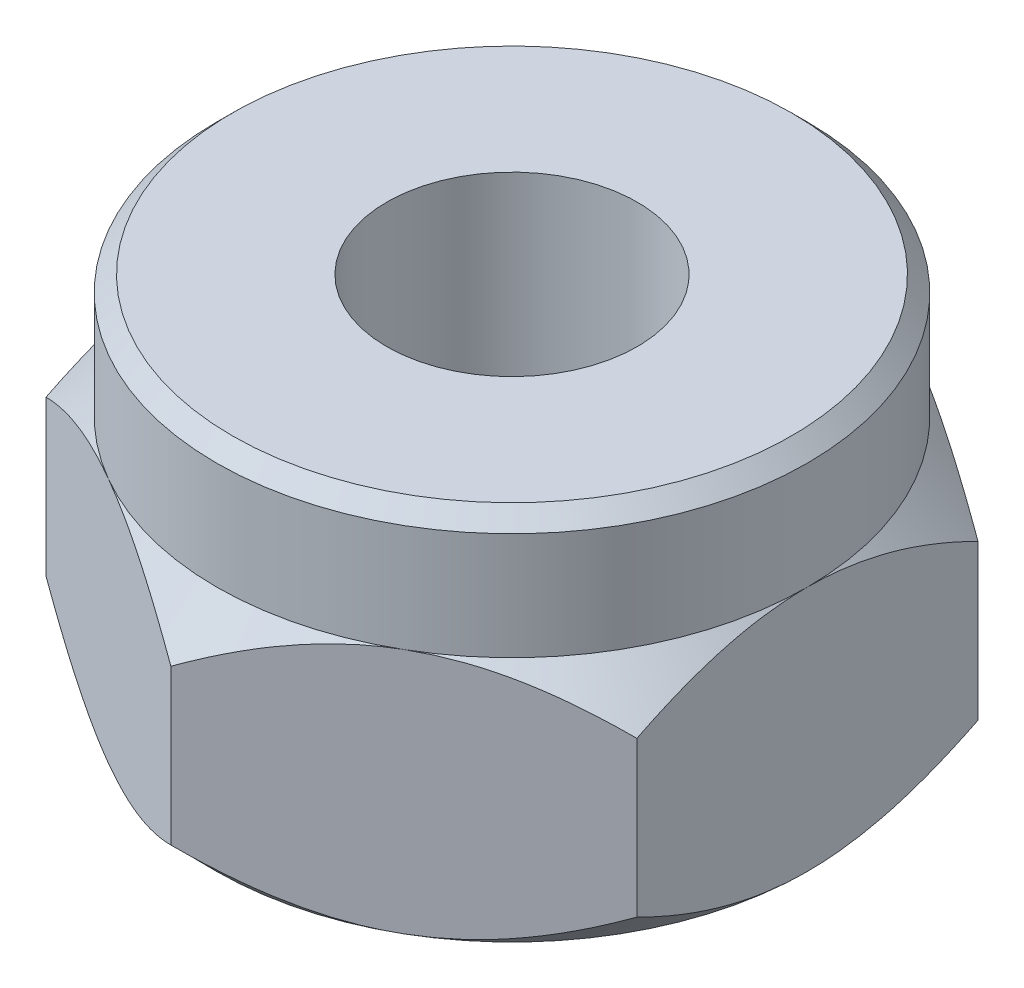
from build123d import *

# Parameters (mm, degrees)
EXTRUDE1_DEPTH              = 1.98501
SKETCH2_OUTSIDE_W           = 22.481
SKETCH2_OUTSIDE_H           = 23.954
SKETCH2_OUTSIDE_R           = 4.7625
EXTRUDE3_DEPTH              = 3.97002
EXTRUDE3_TAPER              = 45
SKETCH3_R                   = 4.7625
EXTRUDE4_DEPTH              = 1.984375
F_21_0_159_DIAMETER_HOLE1_D = 4.0386
CHAMFER1_SIZE               = 0.254


with BuildPart() as part:
    # Sketch1 → Extrude1 (new body, symmetric)
    with BuildSketch(Plane(origin=(0, 0, 0), x_dir=(1, 0, 0), z_dir=(0, 1, 0))):
        Polygon((0, 5.499261314), (-4.7625, 2.749630657), (-4.7625, -2.749630657), (0, -5.499261314), (4.7625, -2.749630657), (4.7625, 2.749630657), align=None)
    extrude(amount=EXTRUDE1_DEPTH, both=True)

    # Sketch2 outside → Extrude3 (cut)
    with BuildSketch(Plane(origin=(0, 1.98501, 0), x_dir=(1, 0, 0), z_dir=(0, 1, 0))):
        with Locations((-0.0005, 0)):
            Rectangle(SKETCH2_OUTSIDE_W, SKETCH2_OUTSIDE_H)
        Circle(SKETCH2_OUTSIDE_R, mode=Mode.SUBTRACT)
    extrude3 = extrude(amount=-EXTRUDE3_DEPTH, taper=EXTRUDE3_TAPER, mode=Mode.SUBTRACT)

    # Mirror1: Extrude3 across plane
    add(extrude3.mirror(Plane.ZX), mode=Mode.SUBTRACT)

    # Sketch3 → Extrude4 (add)
    with BuildSketch(Plane(origin=(0, 1.98501, 0), x_dir=(1, 0, 0), z_dir=(0, 1, 0))):
        Circle(SKETCH3_R)
    extrude(amount=EXTRUDE4_DEPTH)

    # #21 (0.159) Diameter Hole1 (through all)
    with Locations(Plane(origin=(0, 3.969385, 0), x_dir=(-1, 0, 0), z_dir=(0, 1, 0))):
        with Locations((0, 0)):
            Hole(F_21_0_159_DIAMETER_HOLE1_D / 2)

    # Chamfer1
    chamfer1_edges = [part.edges().sort_by_distance(p)[0] for p in [
        (-4.7625, 3.969385, 0),
    ]]
    chamfer(chamfer1_edges, length=CHAMFER1_SIZE)


solid = part.part
